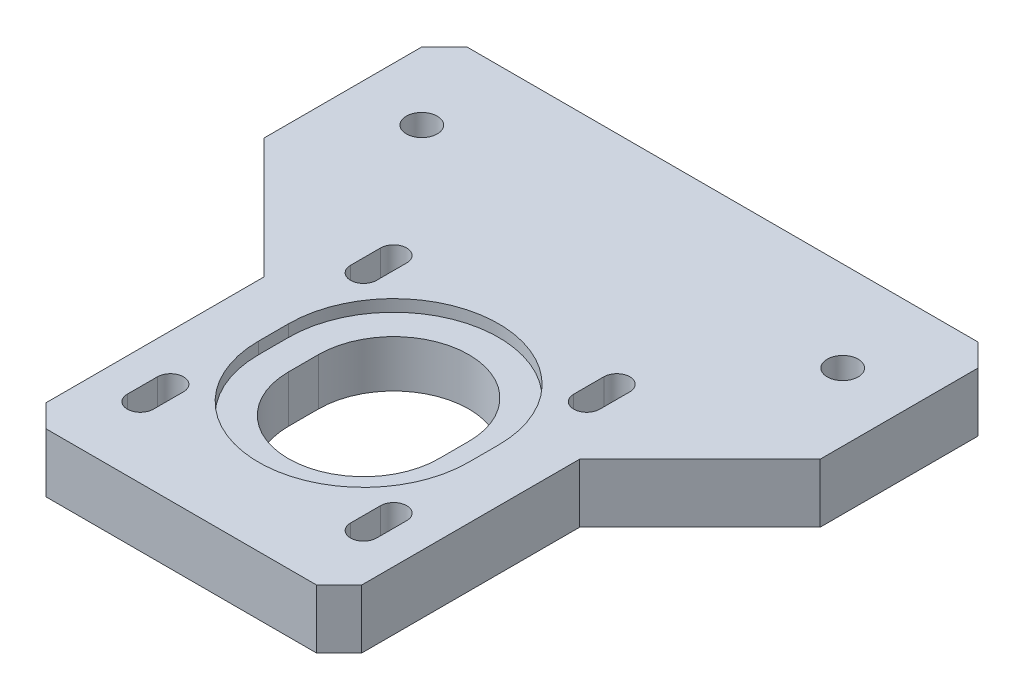
from build123d import *

# Parameters (mm, degrees)
BOSS_EXTRUDE1_DEPTH      = 6.35
F_5_16_18_TAPPED_HOLE1_D = 6.5278
CUT_EXTRUDE1_START       = -0.25
CUT_EXTRUDE1_DEPTH       = 0.25
CUT_EXTRUDE5_DEPTH       = 13.45
CUT_EXTRUDE6_DEPTH       = 5.00000016
CUT_EXTRUDE3_DEPTH       = 2.5
CUT_EXTRUDE4_DEPTH       = 10.95
CHAMFER1_SIZE            = 4.7625


with BuildPart() as part:
    # Sketch1 → Boss-Extrude1 (new body, symmetric)
    with BuildSketch(Plane(origin=(0, 0, 0), x_dir=(1, 0, 0), z_dir=(0, 1, 0))):
        Polygon((-33.3375, 57.15), (-58.7375, 57.15), (-58.7375, 19.05), (-33.3375, -6.35), (-33.3375, -57.15), (33.3375, -57.15), (33.3375, -6.35), (58.7375, 19.05), (58.7375, 57.15), (33.3375, 57.15), align=None)
    extrude(amount=BOSS_EXTRUDE1_DEPTH, both=True)

    # 5/16-18 Tapped Hole1 (through all)
    with Locations(Plane(origin=(0, 6.35, 0), x_dir=(1, 0, 0), z_dir=(0, 1, 0))):
        with Locations((-44.45, 38.1), (44.45, 38.1)):
            Hole(F_5_16_18_TAPPED_HOLE1_D / 2)

    # Sketch4 → Cut-Extrude1 (cut)
    with BuildSketch(Plane(origin=(0, 6.35, 0), x_dir=(1, 0, 0), z_dir=(0, 1, 0)).offset(CUT_EXTRUDE1_START)):
        Polygon((33.3375, -57.15), (33.3375, -6.35), (58.7375, 19.05), (58.7375, 57.15), (-58.7375, 57.15), (-58.7375, 19.05), (-33.3375, -6.35), (-33.3375, -57.15), align=None)
    extrude(amount=CUT_EXTRUDE1_DEPTH, mode=Mode.SUBTRACT)

    # Sketch12 → Cut-Extrude5 (cut, through all)
    with BuildSketch(Plane.XZ.offset(6.35)):
        with BuildLine():
            Line((26.324, -4.92), (26.324, -11.27))
            ThreePointArc((26.324, -11.27), (23.57, -14.024), (20.816, -11.27))
            Line((20.816, -11.27), (20.816, -4.92))
            ThreePointArc((20.816, -4.92), (23.57, -2.166), (26.324, -4.92))
        make_face()
        with BuildLine():
            Line((20.816, 35.87), (20.816, 42.22))
            ThreePointArc((20.816, 42.22), (23.57, 44.974), (26.324, 42.22))
            Line((26.324, 42.22), (26.324, 35.87))
            ThreePointArc((26.324, 35.87), (23.57, 33.116), (20.816, 35.87))
        make_face()
    cut_extrude5 = extrude(amount=-CUT_EXTRUDE5_DEPTH, mode=Mode.SUBTRACT)

    # Sketch13 → Cut-Extrude6 (cut)
    with BuildSketch(Plane.XZ.offset(6.35)):
        with BuildLine():
            Line((19.069999983, -15.945999919), (19.069999983, -0.244000081))
            ThreePointArc((19.069999983, -0.244000081), (23.57, 4.255999936), (28.070000017, -0.244000081))
            Line((28.070000017, -0.244000081), (28.070000017, -15.945999919))
            ThreePointArc((28.070000017, -15.945999919), (23.57, -20.445999936), (19.069999983, -15.945999919))
        make_face()
        with BuildLine():
            Line((19.069999983, 31.194000081), (19.069999983, 46.895999919))
            ThreePointArc((19.069999983, 46.895999919), (23.57, 51.395999936), (28.070000017, 46.895999919))
            Line((28.070000017, 46.895999919), (28.070000017, 31.194000081))
            ThreePointArc((28.070000017, 31.194000081), (23.57, 26.694000064), (19.069999983, 31.194000081))
        make_face()
    cut_extrude6 = extrude(amount=-CUT_EXTRUDE6_DEPTH, mode=Mode.SUBTRACT)

    # Mirror1: Cut-Extrude5, Cut-Extrude6 across plane
    add(cut_extrude5.mirror(Plane(origin=(0, 0, 0), x_dir=(0, 0, 1), z_dir=(1, 0, 0))), mode=Mode.SUBTRACT)
    add(cut_extrude6.mirror(Plane(origin=(0, 0, 0), x_dir=(0, 0, 1), z_dir=(1, 0, 0))), mode=Mode.SUBTRACT)

    # Sketch8 → Cut-Extrude3 (cut)
    with BuildSketch(Plane(origin=(0, 6.1, 0), x_dir=(1, 0, 0), z_dir=(0, 1, 0))):
        with BuildLine():
            Line((-22.175, -18.65), (-22.175, -12.3))
            ThreePointArc((-22.175, -12.3), (0, 9.875), (22.175, -12.3))
            Line((22.175, -12.3), (22.175, -18.65))
            ThreePointArc((22.175, -18.65), (0, -40.825), (-22.175, -18.65))
        make_face()
    extrude(amount=-CUT_EXTRUDE3_DEPTH, mode=Mode.SUBTRACT)

    # Sketch9 → Cut-Extrude4 (cut, through all)
    with BuildSketch(Plane(origin=(0, 3.6, 0), x_dir=(1, 0, 0), z_dir=(0, 1, 0))):
        with BuildLine():
            Line((-15.875, -18.65), (-15.875, -12.3))
            ThreePointArc((-15.875, -12.3), (0, 3.575), (15.875, -12.3))
            Line((15.875, -12.3), (15.875, -18.65))
            ThreePointArc((15.875, -18.65), (0, -34.525), (-15.875, -18.65))
        make_face()
    extrude(amount=-CUT_EXTRUDE4_DEPTH, mode=Mode.SUBTRACT)

    # Chamfer1
    chamfer1_edges = [part.edges().sort_by_distance(p)[0] for p in [
        (33.3375, -0.125, 57.15),
        (-33.3375, -0.125, 57.15),
        (-58.7375, -0.125, -57.15),
        (58.7375, -0.125, -57.15),
    ]]
    chamfer(chamfer1_edges, length=CHAMFER1_SIZE)


solid = part.part
